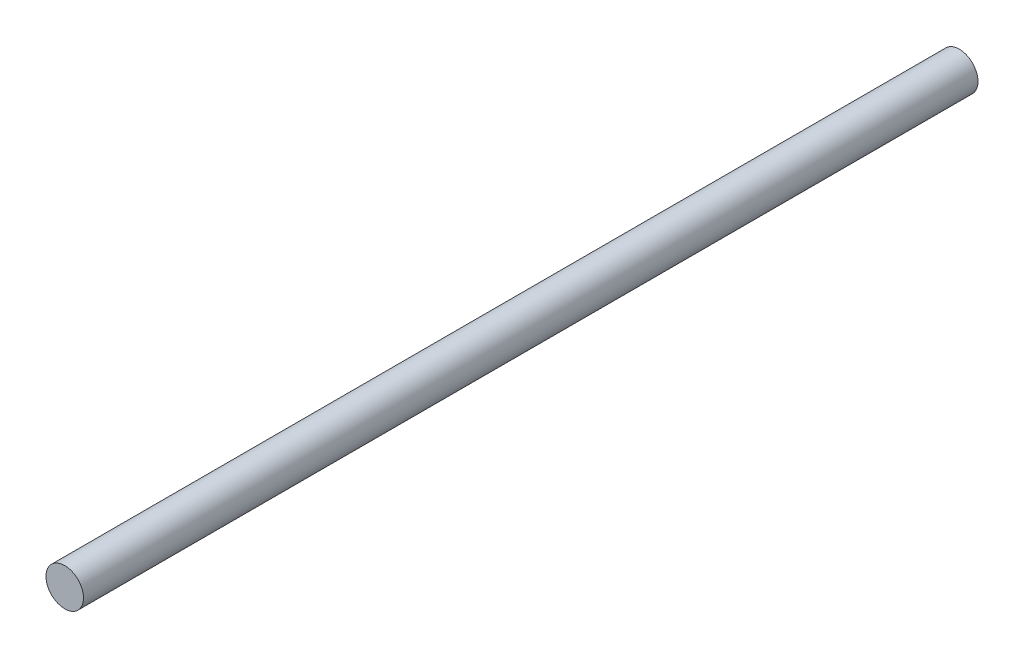
from build123d import *

# Parameters (mm, degrees)
SKETCH1_R           = 3.175
BOSS_EXTRUDE1_DEPTH = 151.384


with BuildPart() as part:
    # Sketch1 → Boss-Extrude1 (new body)
    with BuildSketch(Plane.XY):
        Circle(SKETCH1_R)
    extrude(amount=BOSS_EXTRUDE1_DEPTH)


solid = part.part
